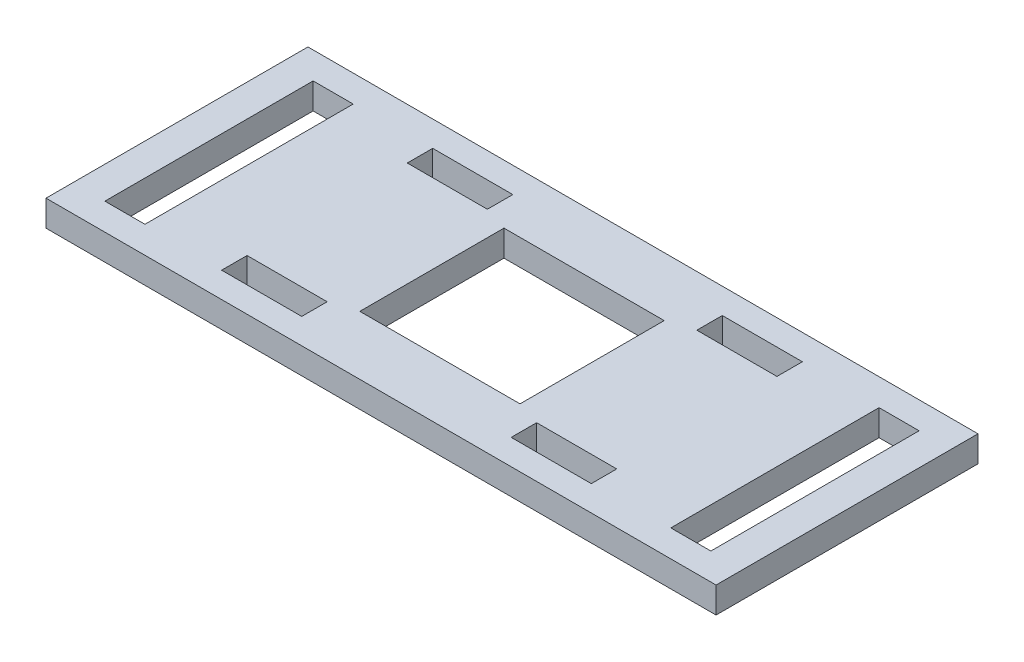
from build123d import *

# Parameters (mm, degrees)
SKETCH1_W           = 83.65
SKETCH1_H           = 32.7
SKETCH1_W_2         = 5
SKETCH1_H_2         = 26
SKETCH1_W_3         = 10
SKETCH1_H_3         = 3.175
SKETCH1_W_4         = 20
SKETCH1_H_4         = 18
BOSS_EXTRUDE1_DEPTH = 3.25


with BuildPart() as part:
    # Sketch1 → Boss-Extrude1 (new body)
    with BuildSketch(Plane(origin=(0, 0, 0), x_dir=(1, 0, 0), z_dir=(0, 1, 0))):
        Rectangle(SKETCH1_W, SKETCH1_H)
        with Locations((-35.325, 0)):
            Rectangle(SKETCH1_W_2, SKETCH1_H_2, mode=Mode.SUBTRACT)
        with Locations((-18.075, 11.5875)):
            Rectangle(SKETCH1_W_3, SKETCH1_H_3, mode=Mode.SUBTRACT)
        with Locations((35.325, 0)):
            Rectangle(SKETCH1_W_2, SKETCH1_H_2, mode=Mode.SUBTRACT)
        with Locations((18.075, 11.5875)):
            Rectangle(SKETCH1_W_3, SKETCH1_H_3, mode=Mode.SUBTRACT)
        with Locations((18.075, -11.5875)):
            Rectangle(SKETCH1_W_3, SKETCH1_H_3, mode=Mode.SUBTRACT)
        with Locations((-18.075, -11.5875)):
            Rectangle(SKETCH1_W_3, SKETCH1_H_3, mode=Mode.SUBTRACT)
        Rectangle(SKETCH1_W_4, SKETCH1_H_4, mode=Mode.SUBTRACT)
    extrude(amount=BOSS_EXTRUDE1_DEPTH)


solid = part.part
